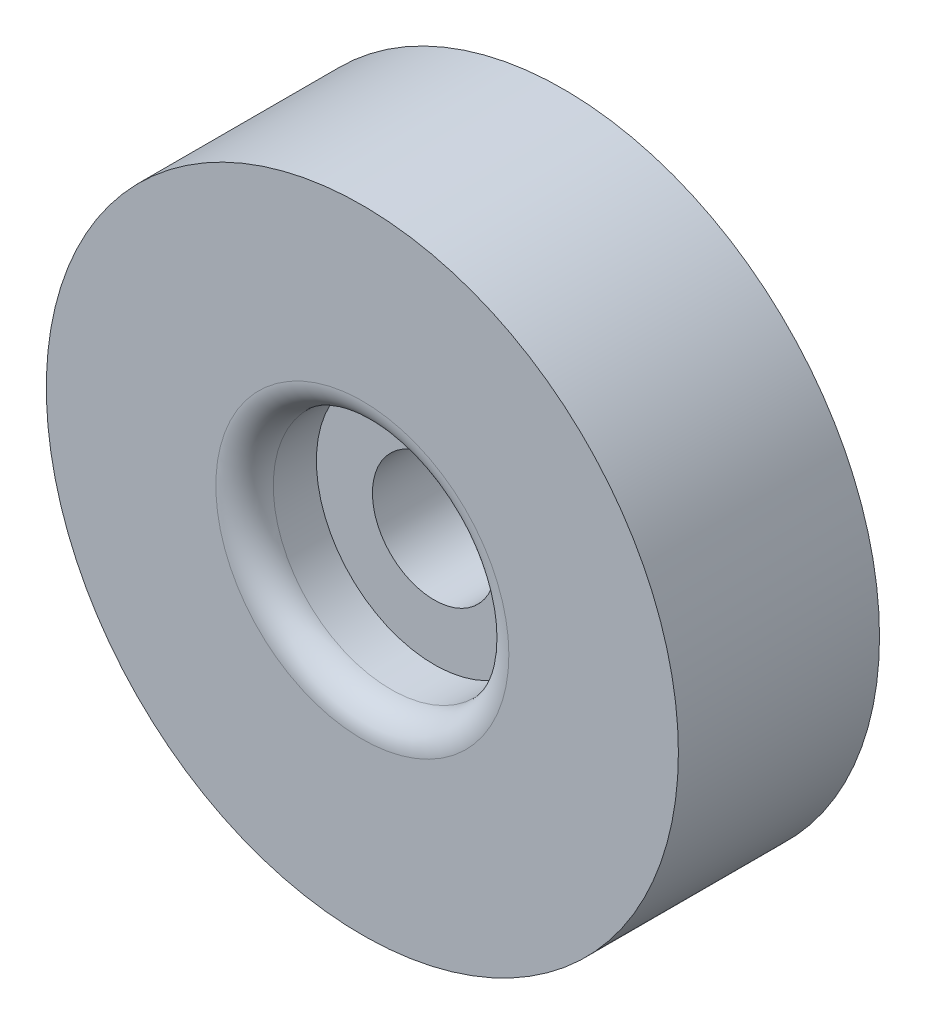
from build123d import *

# Parameters (mm, degrees)
SKETCH1_R           = 11
BOSS_EXTRUDE1_DEPTH = 7
SKETCH2_R           = 4.1
CUT_EXTRUDE1_DEPTH  = 2.5
SKETCH3_R           = 2.15
CUT_EXTRUDE2_DEPTH  = 5.5
FILLET1_R           = 1


with BuildPart() as part:
    # Sketch1 → Boss-Extrude1 (new body)
    with BuildSketch(Plane.XY):
        Circle(SKETCH1_R)
    extrude(amount=BOSS_EXTRUDE1_DEPTH)

    # Sketch2 → Cut-Extrude1 (cut)
    with BuildSketch(Plane.XY.offset(7)):
        Circle(SKETCH2_R)
    extrude(amount=-CUT_EXTRUDE1_DEPTH, mode=Mode.SUBTRACT)

    # Sketch3 → Cut-Extrude2 (cut, through all)
    with BuildSketch(Plane.XY.offset(4.5)):
        Circle(SKETCH3_R)
    extrude(amount=-CUT_EXTRUDE2_DEPTH, mode=Mode.SUBTRACT)

    # Fillet1
    fillet1_edges = [part.edges().sort_by_distance(p)[0] for p in [
        (-4.1, 0, 7),
    ]]
    fillet(fillet1_edges, radius=FILLET1_R)


solid = part.part
